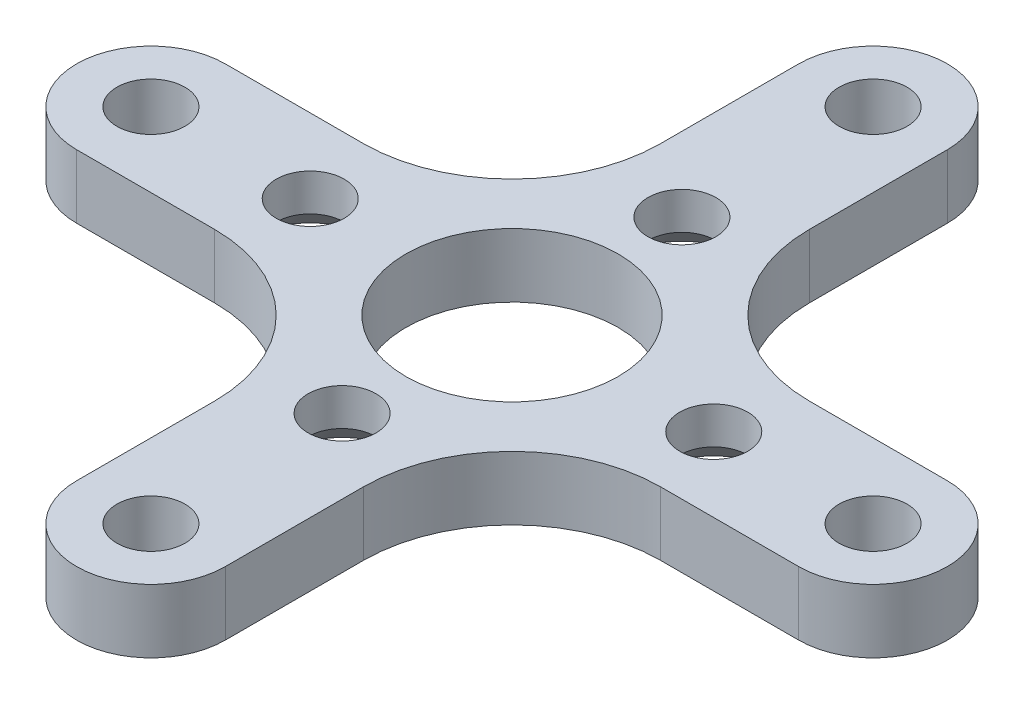
from build123d import *

# Parameters (mm, degrees)
BOSS_EXTRUDE1_DEPTH                             = 3
F_10_0_10_DIAMETER_HOLE1_D                      = 10
F_10_0_10_DIAMETER_HOLE1_DEPTH                  = 10
F_10_0_10_DIAMETER_HOLE1_TIP                    = 3.004303095
CIRPATTERN1_COUNT                               = 4
CSK_FOR_M3_FLAT_HEAD_MACHINE_SCREW1_D           = 3.2
CSK_FOR_M3_FLAT_HEAD_MACHINE_SCREW1_CSINK_D     = 5.7
CSK_FOR_M3_FLAT_HEAD_MACHINE_SCREW1_CSINK_ANGLE = 90


with BuildPart() as part:
    # Sketch1 → Boss-Extrude1 (new body)
    with BuildSketch(Plane(origin=(0, 0, 0), x_dir=(1, 0, 0), z_dir=(0, 1, 0))):
        with BuildLine():
            ThreePointArc((-3.5, -17), (0, -20.5), (3.5, -17))
            Line((3.5, -17), (3.5, -10.5))
            ThreePointArc((3.5, -10.5), (5.550252532, -5.550252532), (10.5, -3.5))
            Line((10.5, -3.5), (17, -3.5))
            ThreePointArc((17, -3.5), (20.5, 0), (17, 3.5))
            Line((17, 3.5), (10.5, 3.5))
            ThreePointArc((10.5, 3.5), (5.550252532, 5.550252532), (3.5, 10.5))
            Line((3.5, 10.5), (3.5, 17))
            ThreePointArc((3.5, 17), (0, 20.5), (-3.5, 17))
            Line((-3.5, 17), (-3.5, 10.5))
            ThreePointArc((-3.5, 10.5), (-5.550252532, 5.550252532), (-10.5, 3.5))
            Line((-10.5, 3.5), (-17, 3.5))
            ThreePointArc((-17, 3.5), (-20.5, 0), (-17, -3.5))
            Line((-17, -3.5), (-10.5, -3.5))
            ThreePointArc((-10.5, -3.5), (-5.550252532, -5.550252532), (-3.5, -10.5))
            Line((-3.5, -10.5), (-3.5, -17))
        make_face()
    extrude(amount=BOSS_EXTRUDE1_DEPTH)

    # Ø10.0 (10) Diameter Hole1
    with Locations(Plane(origin=(0, 0, 0), x_dir=(0, 0, -1), z_dir=(0, -1, 0))):
        with Locations((0, 0)):
            Hole(F_10_0_10_DIAMETER_HOLE1_D / 2, depth=F_10_0_10_DIAMETER_HOLE1_DEPTH)
            with Locations((0, 0, -(F_10_0_10_DIAMETER_HOLE1_DEPTH + F_10_0_10_DIAMETER_HOLE1_TIP / 2))):  # 118° drill point
                Cone(0, F_10_0_10_DIAMETER_HOLE1_D / 2, F_10_0_10_DIAMETER_HOLE1_TIP, mode=Mode.SUBTRACT)

    # Sketch8 → Ø3.2 (3.2) Diameter Hole3 (revolve, cut)
    with BuildSketch(Plane(origin=(0, 0, 17), x_dir=(0, 0, -1), z_dir=(1, 0, 0))):
        Polygon((0, 0), (0, 10.96137699), (1.6, 10), (1.6, 0), align=None)
    f_3_2_3_2_diameter_hole3 = revolve(axis=Axis((0, -6.35, 17), (0, 1, 0)), mode=Mode.SUBTRACT)

    # CirPattern1: Ø3.2 (3.2) Diameter Hole3 ×4 about axis
    cirpattern1_axis = Axis((0, 0, 0), (0, 1, 0))
    for i in range(1, CIRPATTERN1_COUNT):
        add(f_3_2_3_2_diameter_hole3.rotate(cirpattern1_axis, i * 360 / CIRPATTERN1_COUNT), mode=Mode.SUBTRACT)

    # CSK for M3 Flat Head Machine Screw1 (through all)
    with Locations(Plane(origin=(0, 0, -8), x_dir=(0, 0, -1), z_dir=(0, -1, 0))):
        with Locations((0, 0), (-16, 0), (-8, -9.5), (-8, 9.5)):
            CounterSinkHole(CSK_FOR_M3_FLAT_HEAD_MACHINE_SCREW1_D / 2, CSK_FOR_M3_FLAT_HEAD_MACHINE_SCREW1_CSINK_D / 2, counter_sink_angle=CSK_FOR_M3_FLAT_HEAD_MACHINE_SCREW1_CSINK_ANGLE)


solid = part.part
